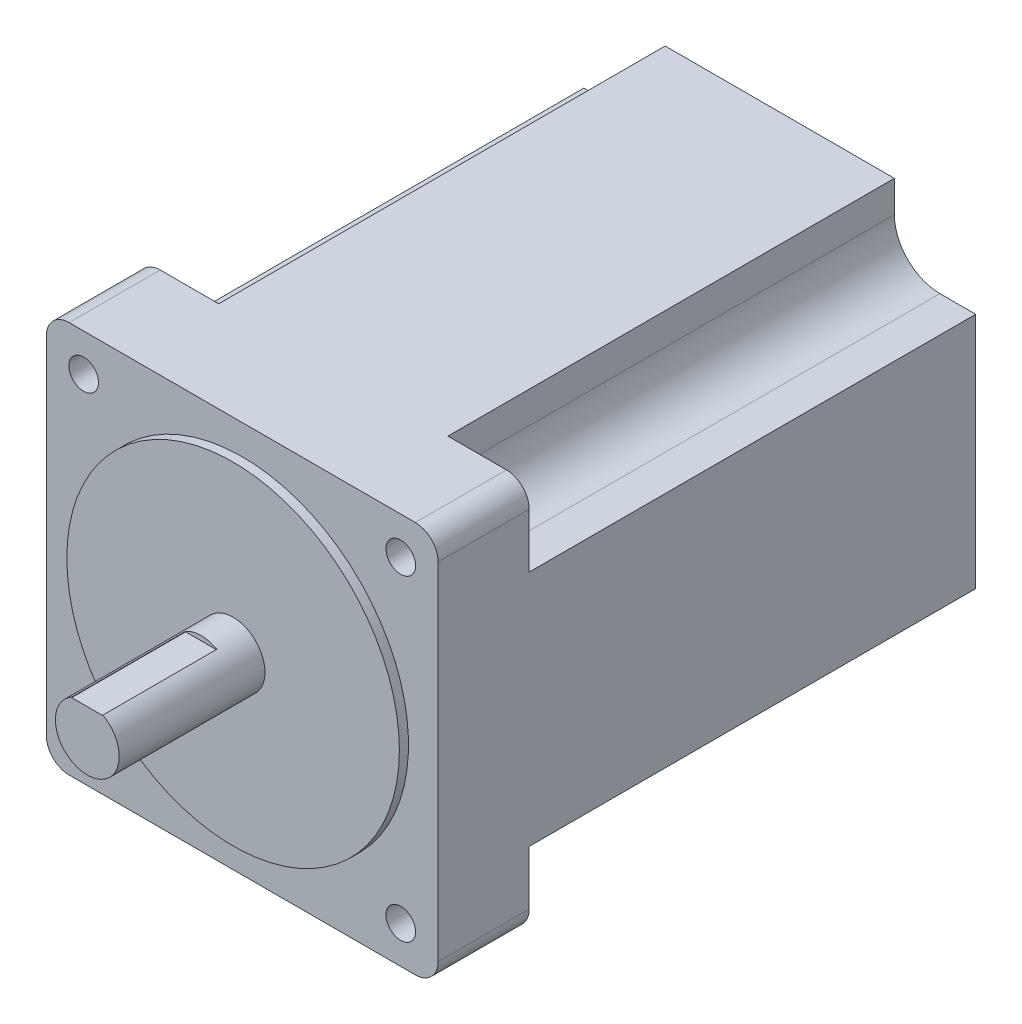
from build123d import *

# Parameters (mm, degrees)
SKETCH_1_W          = 86
SKETCH_1_H          = 86
EXTRUDE_1_DEPTH     = 118
FILLET_1_R          = 5
SKETCH_2_R          = 36.5
EXTRUDE_2_DEPTH     = 2
SKETCH_3_R          = 7
EXTRUDE_3_DEPTH     = 32
SKETCH_4_W          = 6.847911944
SKETCH_4_H          = 3.276194793
CUT_EXTRUDE_1_DEPTH = 25
SKETCH_5_R          = 3.25
CUT_EXTRUDE_2_DEPTH = 119
CUT_EXTRUDE_3_DEPTH = 98


with BuildPart() as part:
    # 草图1 → 凸台-拉伸1 (new body)
    with BuildSketch(Plane.XY):
        with Locations((43, 43)):
            Rectangle(SKETCH_1_W, SKETCH_1_H)
    extrude(amount=EXTRUDE_1_DEPTH)

    # 圆角1
    fillet_1_edges = [part.edges().sort_by_distance(p)[0] for p in [
        (0, 86, 59),
        (86, 86, 59),
        (86, 0, 59),
        (0, 0, 59),
    ]]
    fillet(fillet_1_edges, radius=FILLET_1_R)

    # 草图2 → 凸台-拉伸2 (add)
    with BuildSketch(Plane.XY.offset(118)):
        with Locations((43, 43)):
            Circle(SKETCH_2_R)
    extrude(amount=EXTRUDE_2_DEPTH)

    # 草图3 → 凸台-拉伸3 (add)
    with BuildSketch(Plane.XY.offset(120)):
        with Locations((43, 43)):
            Circle(SKETCH_3_R)
    extrude(amount=EXTRUDE_3_DEPTH)

    # 草图4 → 切除-拉伸1 (cut)
    with BuildSketch(Plane.XY.offset(152)):
        with Locations((43, 50.638097397)):
            Rectangle(SKETCH_4_W, SKETCH_4_H)
    extrude(amount=-CUT_EXTRUDE_1_DEPTH, mode=Mode.SUBTRACT)

    # 草图5 → 切除-拉伸2 (cut, through all)
    with BuildSketch(Plane.XY.offset(118)):
        with Locations((8.2, 77.8)):
            Circle(SKETCH_5_R)
        with Locations((77.8, 77.8)):
            Circle(SKETCH_5_R)
        with Locations((77.8, 8.2)):
            Circle(SKETCH_5_R)
        with Locations((8.2, 8.2)):
            Circle(SKETCH_5_R)
    extrude(amount=-CUT_EXTRUDE_2_DEPTH, mode=Mode.SUBTRACT)

    # 草图6 → 切除-拉伸3 (cut)
    with BuildSketch(Plane(origin=(0, 0, 0), x_dir=(-1, 0, 0), z_dir=(0, 0, -1))):
        with BuildLine():
            Line((-68.156525259, 86), (-93.025218422, 86))
            Line((-93.025218422, 86), (-93.025218422, 69.077587969))
            Line((-93.025218422, 69.077587969), (-78.156525259, 69.077587969))
            ThreePointArc((-78.156525259, 69.077587969), (-71.085457448, 72.006520157), (-68.156525259, 79.077587969))
            Line((-68.156525259, 79.077587969), (-68.156525259, 86))
        make_face()
        with BuildLine():
            Line((-17.843474741, 86), (-17.843474741, 79.077587969))
            ThreePointArc((-17.843474741, 79.077587969), (-14.914542552, 72.006520157), (-7.843474741, 69.077587969))
            Line((-7.843474741, 69.077587969), (7.025218422, 69.077587969))
            Line((7.025218422, 69.077587969), (7.025218422, 86))
            Line((7.025218422, 86), (-17.843474741, 86))
        make_face()
        with BuildLine():
            Line((-7.843474741, 16.922412031), (7.025218422, 16.922412031))
            Line((7.025218422, 16.922412031), (7.025218422, 0))
            Line((7.025218422, 0), (-17.843474741, 0))
            Line((-17.843474741, 0), (-17.843474741, 6.922412031))
            ThreePointArc((-17.843474741, 6.922412031), (-14.914542552, 13.993479843), (-7.843474741, 16.922412031))
        make_face()
        with BuildLine():
            Line((-68.156525259, 0), (-68.156525259, 6.922412031))
            ThreePointArc((-68.156525259, 6.922412031), (-71.085457448, 13.993479843), (-78.156525259, 16.922412031))
            Line((-78.156525259, 16.922412031), (-93.025218422, 16.922412031))
            Line((-93.025218422, 16.922412031), (-93.025218422, 0))
            Line((-93.025218422, 0), (-68.156525259, 0))
        make_face()
    extrude(amount=-CUT_EXTRUDE_3_DEPTH, mode=Mode.SUBTRACT)


solid = part.part
